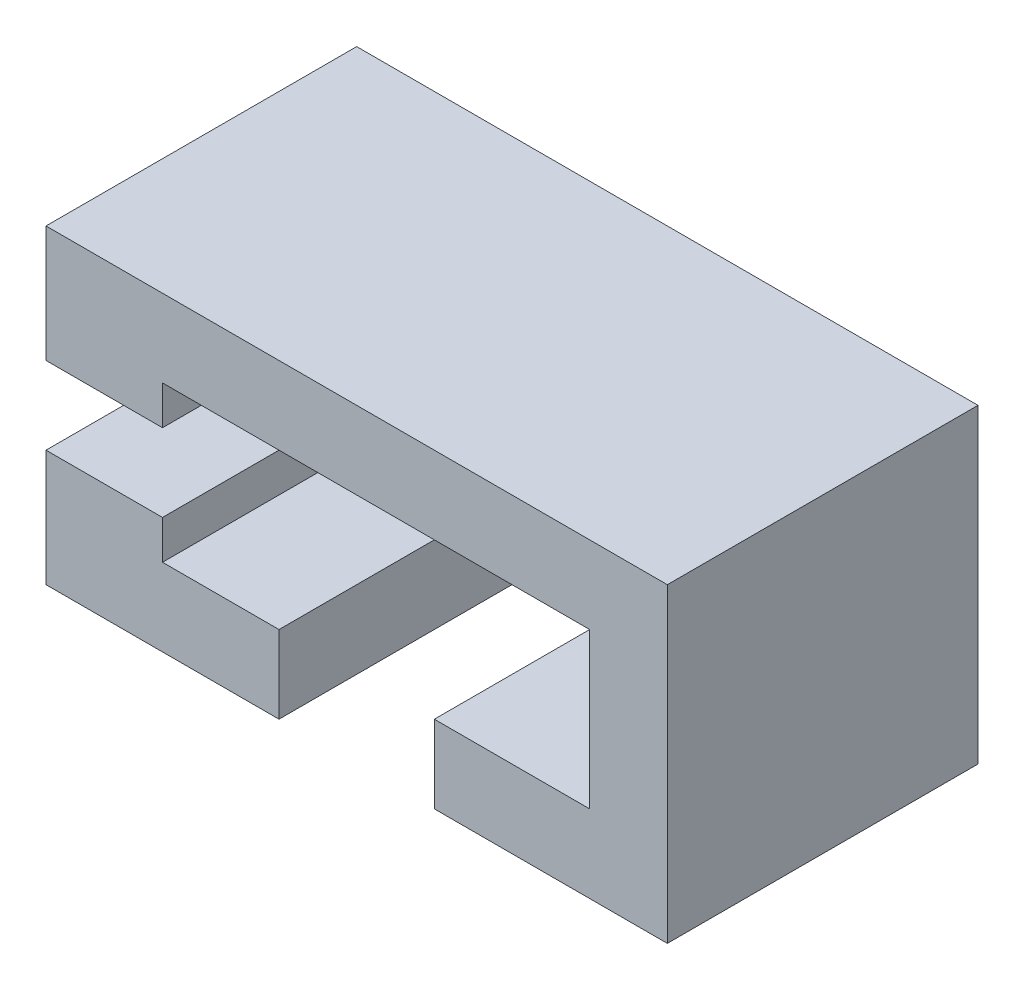
from build123d import *

# Parameters (mm, degrees)
BOSS_EXTRUDE1_DEPTH = 80
SKETCH3_W           = 20
SKETCH3_H           = 40
CUT_EXTRUDE1_DEPTH  = 25
SKETCH4_W           = 55
SKETCH4_H           = 5
CUT_EXTRUDE2_DEPTH  = 40
SKETCH6_W           = 20
SKETCH6_H           = 5
CUT_EXTRUDE3_DEPTH  = 40
SKETCH7_W           = 20
SKETCH7_H           = 10
CUT_EXTRUDE4_DEPTH  = 20
SKETCH8_W           = 10
SKETCH8_H           = 10
BOSS_EXTRUDE2_DEPTH = 20
SKETCH9_W           = 15
SKETCH9_H           = 10
CUT_EXTRUDE5_DEPTH  = 20
SKETCH11_W          = 15
SKETCH11_H          = 5
CUT_EXTRUDE6_DEPTH  = 40


with BuildPart() as part:
    # Sketch1 → Boss-Extrude1 (new body)
    with BuildSketch(Plane(origin=(0, 0, 0), x_dir=(0, 0, -1), z_dir=(1, 0, 0))):
        Polygon((0, 0), (0, -15), (40, -15), (40, 25), (0, 25), (0, 10), (20, 10), (20, 0), align=None)
    extrude(amount=-BOSS_EXTRUDE1_DEPTH)

    # Sketch3 → Cut-Extrude1 (cut)
    with BuildSketch(Plane.XZ.offset(15)):
        with Locations((-40, -20)):
            Rectangle(SKETCH3_W, SKETCH3_H)
    extrude(amount=-CUT_EXTRUDE1_DEPTH, mode=Mode.SUBTRACT)

    # Sketch4 → Cut-Extrude2 (cut)
    with BuildSketch(Plane.XY):
        with Locations((-37.5, 12.5)):
            Rectangle(SKETCH4_W, SKETCH4_H)
    extrude(amount=-CUT_EXTRUDE2_DEPTH, mode=Mode.SUBTRACT)

    # Sketch6 → Cut-Extrude3 (cut)
    with BuildSketch(Plane.XY):
        with Locations((-20, -2.5)):
            Rectangle(SKETCH6_W, SKETCH6_H)
    extrude(amount=-CUT_EXTRUDE3_DEPTH, mode=Mode.SUBTRACT)

    # Sketch7 → Cut-Extrude4 (cut)
    with BuildSketch(Plane.XY.offset(-20)):
        with Locations((-20, 5)):
            Rectangle(SKETCH7_W, SKETCH7_H)
    extrude(amount=-CUT_EXTRUDE4_DEPTH, mode=Mode.SUBTRACT)

    # Sketch8 → Boss-Extrude2 (add)
    with BuildSketch(Plane.XY.offset(-20)):
        with Locations((-5, 5)):
            Rectangle(SKETCH8_W, SKETCH8_H)
    extrude(amount=BOSS_EXTRUDE2_DEPTH)

    # Sketch9 → Cut-Extrude5 (cut)
    with BuildSketch(Plane.XY.offset(-20)):
        with Locations((-57.5, 5)):
            Rectangle(SKETCH9_W, SKETCH9_H)
    extrude(amount=-CUT_EXTRUDE5_DEPTH, mode=Mode.SUBTRACT)

    # Sketch11 → Cut-Extrude6 (cut)
    with BuildSketch(Plane(origin=(0, 0, -40), x_dir=(-1, 0, 0), z_dir=(0, 0, -1))):
        with Locations((57.5, -2.5)):
            Rectangle(SKETCH11_W, SKETCH11_H)
    extrude(amount=-CUT_EXTRUDE6_DEPTH, mode=Mode.SUBTRACT)


solid = part.part
